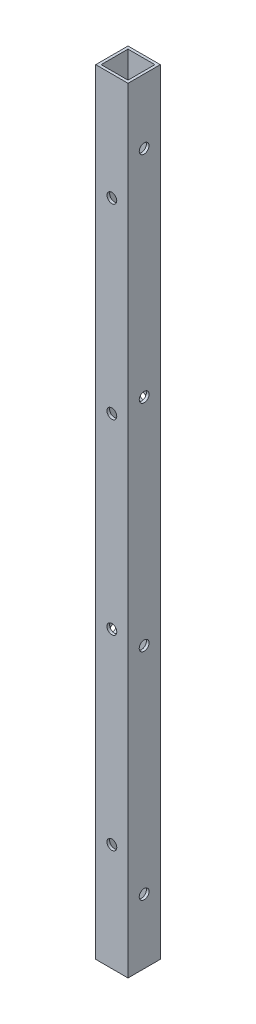
from build123d import *

# Parameters (mm, degrees)
SKETCH1_W                 = 19.05
SKETCH1_H                 = 19.05
SKETCH1_W_2               = 15.875
SKETCH1_H_2               = 15.875
TUBE_DEPTH                = 457.4032
SKETCH2_R                 = 2.8956
TOPPLATEHOLES_DEPTH       = 20.05
LPATTERN1_COUNT           = 4
LPATTERN1_PITCH           = 110.202133333
SKETCH3_R                 = 2.8956
SIDEPLATEHOLEMASTER_DEPTH = 20.05
LPATTERN2_COUNT           = 4
LPATTERN2_PITCH           = 127.067733333


with BuildPart() as part:
    # Sketch1 → Tube (new body)
    with BuildSketch(Plane(origin=(0, 0, 0), x_dir=(1, 0, 0), z_dir=(0, 1, 0))):
        Rectangle(SKETCH1_W, SKETCH1_H)
        Rectangle(SKETCH1_W_2, SKETCH1_H_2, mode=Mode.SUBTRACT)
    extrude(amount=TUBE_DEPTH)

    # Sketch2 → TopPlateHoles (cut, through all)
    with BuildSketch(Plane.XY.offset(9.525)):
        with Locations((0, 394.0048)):
            Circle(SKETCH2_R)
    topplateholes = extrude(amount=-TOPPLATEHOLES_DEPTH, mode=Mode.SUBTRACT)

    # LPattern1: TopPlateHoles ×4
    with Locations(*[(0, -i * LPATTERN1_PITCH, 0) for i in range(1, LPATTERN1_COUNT)]):
        add(topplateholes, mode=Mode.SUBTRACT)

    # Sketch3 → SidePlateHoleMaster (cut, through all)
    with BuildSketch(Plane.ZY.offset(9.525)):
        with Locations((0, 419.3032)):
            Circle(SKETCH3_R)
    sideplateholemaster = extrude(amount=-SIDEPLATEHOLEMASTER_DEPTH, mode=Mode.SUBTRACT)

    # LPattern2: SidePlateHoleMaster ×4
    with Locations(*[(0, -i * LPATTERN2_PITCH, 0) for i in range(1, LPATTERN2_COUNT)]):
        add(sideplateholemaster, mode=Mode.SUBTRACT)


solid = part.part
